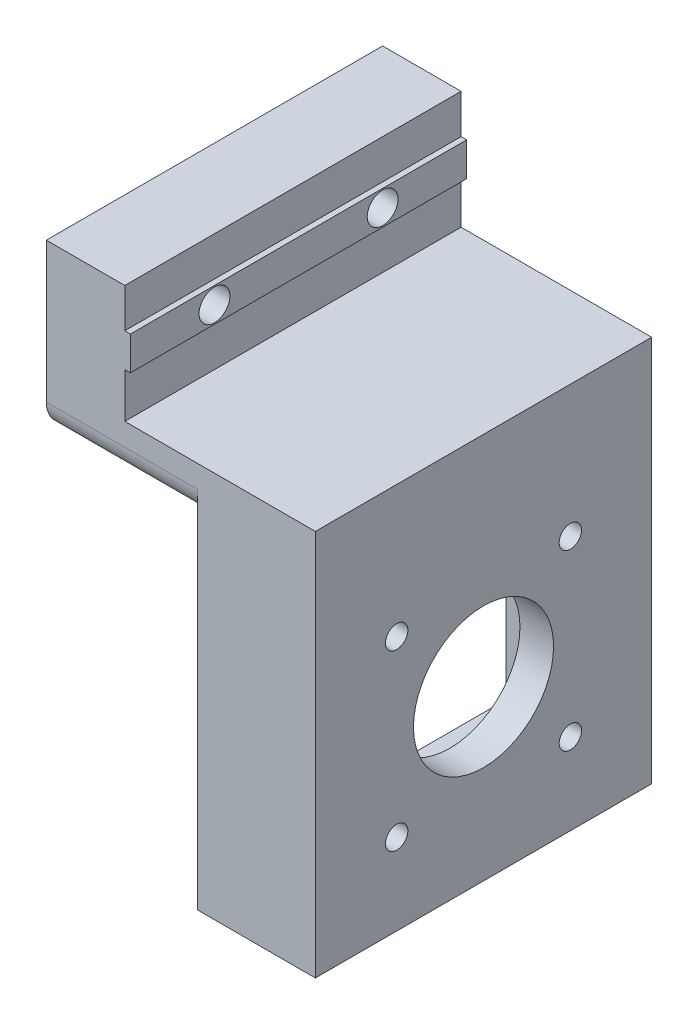
from build123d import *

# Parameters (mm, degrees)
SALIENTE_EXTRUIR1_DEPTH = 60
CORTAR_EXTRUIR1_REACH   = 50
CROQUIS2_R              = 2
CROQUIS2_R_2            = 12.5
SALIENTE_EXTRUIR2_DEPTH = 15
CROQUIS4_W              = 60
CROQUIS4_H              = 6
SALIENTE_EXTRUIR3_DEPTH = 1
CORTAR_EXTRUIR2_REACH   = 50
CROQUIS5_R              = 2.75
CROQUIS6_R              = 6
CORTAR_EXTRUIR3_DEPTH   = 8
REDONDEO1_R             = 5


with BuildPart() as part:
    # Croquis1 → Saliente-Extruir1 (new body)
    with BuildSketch(Plane.XY):
        Polygon((0, 0), (0, -30), (42, -30), (42, -90), (48, -90), (48, -21), (14, -21), (14, 0), align=None)
    extrude(amount=SALIENTE_EXTRUIR1_DEPTH)

    # Croquis2 → Cortar-Extruir1 (cut, up to next)
    with BuildSketch(Plane(origin=(48, 0, 0), x_dir=(0, 0, -1), z_dir=(1, 0, 0)), mode=Mode.PRIVATE) as cortar_extruir1_sk1:
        with Locations((-45.5, -44.5)):
            Circle(CROQUIS2_R)
    cortar_extruir1_tool1 = extrude(cortar_extruir1_sk1.sketch, amount=-CORTAR_EXTRUIR1_REACH, mode=Mode.PRIVATE) & part.part
    add(cortar_extruir1_tool1.solids().sort_by_distance((48, -44.5, 45.5))[0], mode=Mode.SUBTRACT)
    # Croquis2 → Cortar-Extruir1 (cut, up to next)
    with BuildSketch(Plane(origin=(48, 0, 0), x_dir=(0, 0, -1), z_dir=(1, 0, 0)), mode=Mode.PRIVATE) as cortar_extruir1_sk2:
        with Locations((-14.5, -44.5)):
            Circle(CROQUIS2_R)
    cortar_extruir1_tool2 = extrude(cortar_extruir1_sk2.sketch, amount=-CORTAR_EXTRUIR1_REACH, mode=Mode.PRIVATE) & part.part
    add(cortar_extruir1_tool2.solids().sort_by_distance((48, -44.5, 14.5))[0], mode=Mode.SUBTRACT)
    # Croquis2 → Cortar-Extruir1 (cut, up to next)
    with BuildSketch(Plane(origin=(48, 0, 0), x_dir=(0, 0, -1), z_dir=(1, 0, 0)), mode=Mode.PRIVATE) as cortar_extruir1_sk3:
        with Locations((-45.5, -75.5)):
            Circle(CROQUIS2_R)
    cortar_extruir1_tool3 = extrude(cortar_extruir1_sk3.sketch, amount=-CORTAR_EXTRUIR1_REACH, mode=Mode.PRIVATE) & part.part
    add(cortar_extruir1_tool3.solids().sort_by_distance((48, -75.5, 45.5))[0], mode=Mode.SUBTRACT)
    # Croquis2 → Cortar-Extruir1 (cut, up to next)
    with BuildSketch(Plane(origin=(48, 0, 0), x_dir=(0, 0, -1), z_dir=(1, 0, 0)), mode=Mode.PRIVATE) as cortar_extruir1_sk4:
        with Locations((-14.5, -75.5)):
            Circle(CROQUIS2_R)
    cortar_extruir1_tool4 = extrude(cortar_extruir1_sk4.sketch, amount=-CORTAR_EXTRUIR1_REACH, mode=Mode.PRIVATE) & part.part
    add(cortar_extruir1_tool4.solids().sort_by_distance((48, -75.5, 14.5))[0], mode=Mode.SUBTRACT)
    # Croquis2 → Cortar-Extruir1 (cut, up to next)
    with BuildSketch(Plane(origin=(48, 0, 0), x_dir=(0, 0, -1), z_dir=(1, 0, 0)), mode=Mode.PRIVATE) as cortar_extruir1_sk5:
        with Locations((-30, -60)):
            Circle(CROQUIS2_R_2)
    cortar_extruir1_tool5 = extrude(cortar_extruir1_sk5.sketch, amount=-CORTAR_EXTRUIR1_REACH, mode=Mode.PRIVATE) & part.part
    add(cortar_extruir1_tool5.solids().sort_by_distance((48, -60, 30))[0], mode=Mode.SUBTRACT)

    # Croquis3 → Saliente-Extruir2 (add)
    with BuildSketch(Plane.ZY.offset(-42)):
        Polygon((0, -30), (0, -90), (60, -90), (60, -30), (55, -30), (55, -85), (5, -85), (5, -30), align=None)
    extrude(amount=SALIENTE_EXTRUIR2_DEPTH)

    # Croquis4 → Saliente-Extruir3 (add)
    with BuildSketch(Plane(origin=(14, 0, 0), x_dir=(0, 0, -1), z_dir=(1, 0, 0))):
        with Locations((-30, -10)):
            Rectangle(CROQUIS4_W, CROQUIS4_H)
    extrude(amount=SALIENTE_EXTRUIR3_DEPTH)

    # Croquis5 → Cortar-Extruir2 (cut, up to next)
    with BuildSketch(Plane.ZY, mode=Mode.PRIVATE) as cortar_extruir2_sk1:
        with Locations((15, -10)):
            Circle(CROQUIS5_R)
    cortar_extruir2_tool1 = extrude(cortar_extruir2_sk1.sketch, amount=-CORTAR_EXTRUIR2_REACH, mode=Mode.PRIVATE) & part.part
    add(cortar_extruir2_tool1.solids().sort_by_distance((0, -10, 15))[0], mode=Mode.SUBTRACT)
    # Croquis5 → Cortar-Extruir2 (cut, up to next)
    with BuildSketch(Plane.ZY, mode=Mode.PRIVATE) as cortar_extruir2_sk2:
        with Locations((45, -10)):
            Circle(CROQUIS5_R)
    cortar_extruir2_tool2 = extrude(cortar_extruir2_sk2.sketch, amount=-CORTAR_EXTRUIR2_REACH, mode=Mode.PRIVATE) & part.part
    add(cortar_extruir2_tool2.solids().sort_by_distance((0, -10, 45))[0], mode=Mode.SUBTRACT)

    # Croquis6 → Cortar-Extruir3 (cut)
    with BuildSketch(Plane.ZY):
        with Locations((15, -10)):
            Circle(CROQUIS6_R)
        with Locations((45, -10)):
            Circle(CROQUIS6_R)
    extrude(amount=-CORTAR_EXTRUIR3_DEPTH, mode=Mode.SUBTRACT)

    # Redondeo1
    redondeo1_edges = [part.edges().sort_by_distance(p)[0] for p in [
        (13.5, -30, 60),
        (13.5, -30, 0),
    ]]
    fillet(redondeo1_edges, radius=REDONDEO1_R)


solid = part.part
